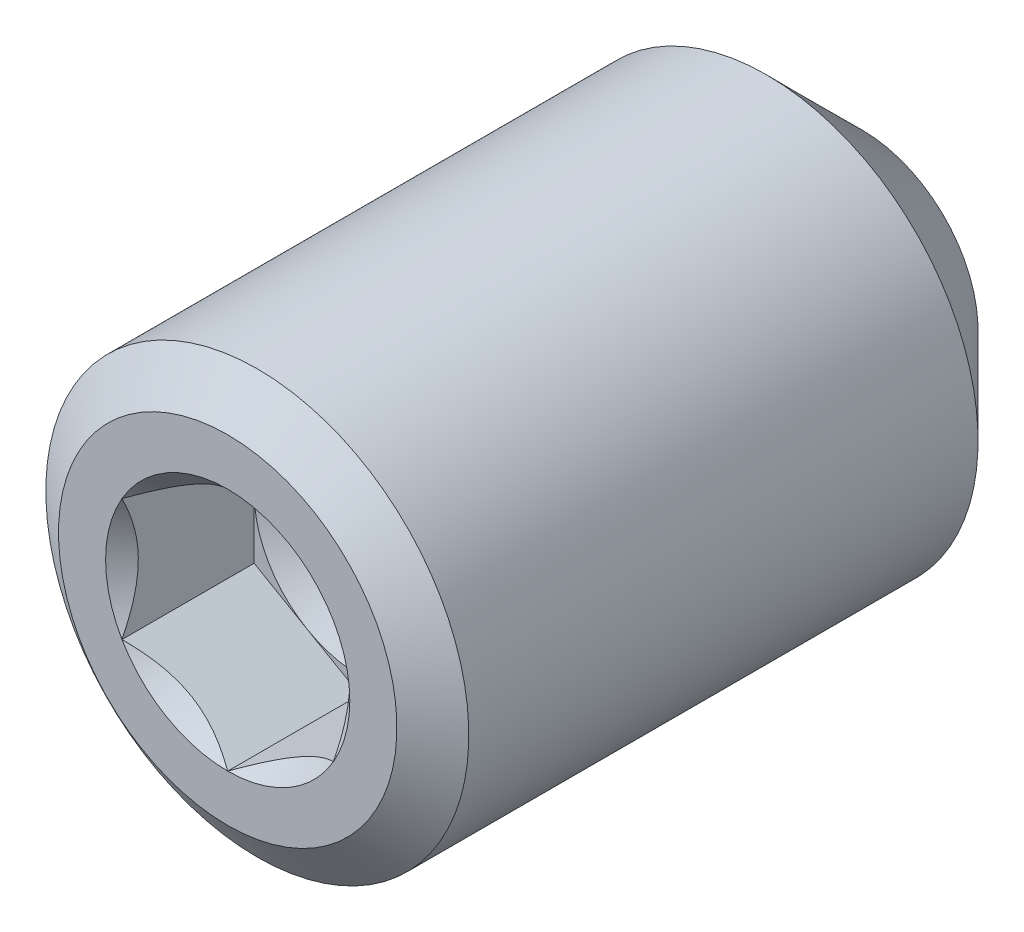
from build123d import *

# Parameters (mm, degrees)
CUT_EXTRUDE10_DEPTH = 1.984375


with BuildPart() as part:
    # Sketch22 → Revolve1 (revolve)
    with BuildSketch(Plane(origin=(0, 0, 0), x_dir=(0, 0, -1), z_dir=(1, 0, 0))):
        Polygon((-4.239814779, 0), (-4.239814779, 2.54), (-3.795182992, 3.175), (3.849973798, 3.175), (5.285185221, 1.739788577), (4.239814779, 0), align=None)
    revolve(axis=Axis((0, 0, -4.239814779), (0, 0, -1)))

    # Sketch23 → Cut-Extrude10 (cut)
    with BuildSketch(Plane.XY.offset(4.239814779)):
        Polygon((0, 1.833087105), (-1.5875, 0.916543552), (-1.5875, -0.916543552), (0, -1.833087105), (1.5875, -0.916543552), (1.5875, 0.916543552), align=None)
    extrude(amount=-CUT_EXTRUDE10_DEPTH, mode=Mode.SUBTRACT)

    # Cut-Extrude11 cone 1 section (through the dimple's axis) → Cut-Extrude11 (revolve, cut)
    with BuildSketch(Plane(origin=(0, 0, 4.239814779), x_dir=(0, -1, 0), z_dir=(1, 0, 0))):
        Polygon((0, 0), (1.833087105, 0), (0, 1.833087105), align=None)
    revolve(axis=Axis((0, 0, 4.239814779), (0, 0, -1)), mode=Mode.SUBTRACT)

    # Cut-Extrude12 cone 1 section (through the dimple's axis) → Cut-Extrude12 (revolve, cut)
    with BuildSketch(Plane(origin=(0, 0, 2.255439779), x_dir=(0, -1, 0), z_dir=(1, 0, 0))):
        Polygon((0, 0), (1.5875, 0), (0, 0.916543552), align=None)
    revolve(axis=Axis((0, 0, 2.255439779), (0, 0, -1)), mode=Mode.SUBTRACT)


solid = part.part
